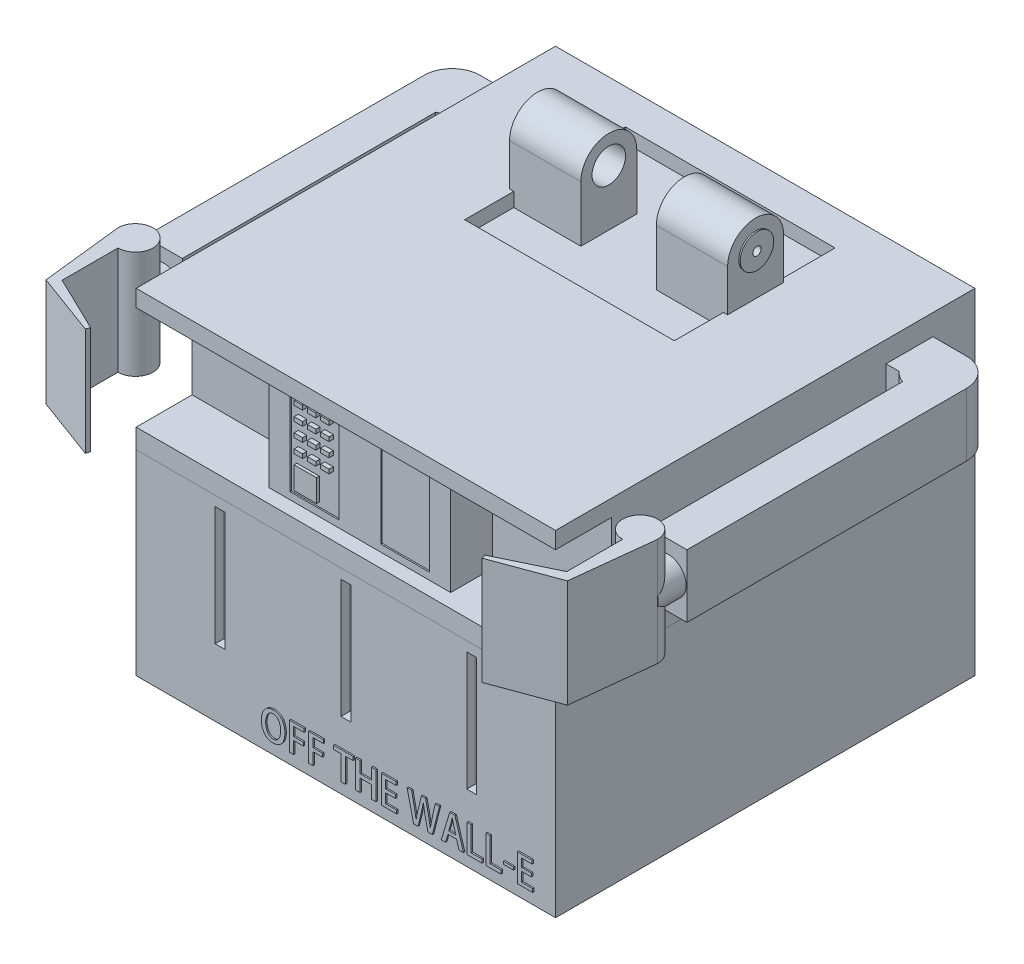
from build123d import *

# Parameters (mm, degrees)
BASE_W                                = 15
BASE_H                                = 15
BOTTOM_BASE_DEPTH                     = 7
BASE2_W                               = 15
BASE2_H                               = 15
TOP_BASE_DEPTH                        = 5
SKETCH3_W                             = 15
SKETCH3_H                             = 3.7
TOP_CUT_DEPTH                         = 2
SKETCH4_W                             = 6.5
SKETCH4_H                             = 3.7
BIG_BUTTON_PLATE_DEPTH                = 1.5
SKETCH6_W                             = 0.3
SKETCH6_H                             = 0.15
F_3X4_BUTTONS_DEPTH                   = 0.1
SKETCH9_W                             = 0.8
SKETCH9_H                             = 0.8
BIG_SQUARE_BUTTON_DEPTH               = 0.1
SKETCH6_6_W                           = 1.75
SKETCH6_6_H                           = 3.2
SKETCH6_6_W_2                         = 0.3
SKETCH6_6_H_2                         = 0.15
PHONE_DEPTH                           = 0.05
SKETCH14_W                            = 0.35
SKETCH14_H                            = 4.25
F_3_BOTTOM_SLOTS_DEPTH                = 0.35
FILLET1_R                             = 0.05
SKETCH15_W                            = 7.5
SKETCH15_H                            = 5.75
TOP_EXTRUDE_CUT_DEPTH                 = 0.5
RIGHT_HEAD_HOLDER_1_DEPTH             = 2.4
RIGHT_HEAD_HOLDER_1_DEPTH_BACK        = 0.15
SKETCH19_R                            = 0.6
RIGHT_HEAD_HOLDER_2_DEPTH             = 0.35
RIGHT_HEAD_HOLDER_2_DEPTH_BACK        = 0.2
SKETCH19_3_R                          = 0.6
SKETCH19_3_R_2                        = 0.15
LEFT_HEAD_HOLDER_1_DEPTH              = 2.4
LEFT_HEAD_HOLDER_1_DEPTH_BACK         = 0.15
SKETCH18_R                            = 0.6
LEFT_HEAD_HOLDER_2_DEPTH              = 0.35
LEFT_HEAD_HOLDER_2_DEPTH_BACK         = 0.2
SKETCH18_3_R                          = 0.6
SKETCH18_3_R_2                        = 0.15
ARMS_DEPTH                            = 2.25
CLAWS_DEPTH                           = 0.8
CLAWS_DEPTH_BACK                      = 3.05
CLAWS_2_DEPTH                         = 0.8
CLAWS_2_DEPTH_BACK                    = 3.05
SKETCH26_R                            = 0.65
CIRCLE_TO_ATTACH_ARMS_AND_CLAWS_DEPTH = 1
SKETCH28_W                            = 0.359189424
SKETCH28_H                            = 0.095238297
BOSS_EXTRUDE26_DEPTH                  = 0.05
SKETCH33_W                            = 1
SKETCH33_H                            = 1
CUT_EXTRUDE1_DEPTH                    = 2.25


with BuildPart() as part:
    # Base → Bottom base (new body)
    with BuildSketch(Plane(origin=(0, 0, 0), x_dir=(1, 0, 0), z_dir=(0, 1, 0))):
        Rectangle(BASE_W, BASE_H)
    extrude(amount=BOTTOM_BASE_DEPTH)

    # Sketch14 → 3 bottom slots (cut)
    with BuildSketch(Plane.XY.offset(7.5)):
        with Locations((0, 4.525)):
            Rectangle(SKETCH14_W, SKETCH14_H)
        with Locations((4.5, 4.525)):
            Rectangle(SKETCH14_W, SKETCH14_H)
        with Locations((-4.5, 4.525)):
            Rectangle(SKETCH14_W, SKETCH14_H)
    extrude(amount=-F_3_BOTTOM_SLOTS_DEPTH, mode=Mode.SUBTRACT)

    # Fillet1
    fillet1_edges = [part.edges().sort_by_distance(p)[0] for p in [
        (-0.175, 4.525, 7.15),
        (-4.675, 4.525, 7.15),
        (4.675, 4.525, 7.15),
        (4.5, 6.65, 7.15),
        (0.175, 4.525, 7.15),
        (0, 6.65, 7.15),
        (4.325, 4.525, 7.15),
        (4.5, 2.4, 7.15),
        (0, 2.4, 7.15),
        (-4.5, 2.4, 7.15),
        (-4.5, 6.65, 7.15),
        (-4.325, 4.525, 7.15),
    ]]
    fillet(fillet1_edges, radius=FILLET1_R)

    # Sketch28 → Boss-Extrude26 (add)
    # profile 1 of 12: a face of its own
    with BuildSketch(Plane.XY.offset(7.5)):
        with BuildLine():
            add(Edge.make_bspline(
                [(-2.542773415, 1.438775136), (-2.55882584, 1.438110923), (-2.59017136, 1.436813916), (-2.635834672, 1.429654226), (-2.678976734, 1.41865114), (-2.719463386, 1.403035452), (-2.757423202, 1.38326681), (-2.792716073, 1.359116703), (-2.825399223, 1.330752787), (-2.855279169, 1.298345473), (-2.882055278, 1.262197262), (-2.905669966, 1.222690536), (-2.925377124, 1.17977718), (-2.941932195, 1.133846801), (-2.954655386, 1.08466898), (-2.964079137, 1.032377645), (-2.969951963, 0.976854424), (-2.97105014, 0.938758011), (-2.971613422, 0.919217401)],
                knots=[0, 0, 0, 0, 1.01693825, 1.985772131, 2.921518734, 3.832117633, 4.727948323, 5.626511184, 6.534414133, 7.463288783, 8.412839634, 9.378967074, 10.373196777, 11.399194858, 12.46754142, 13.586614818, 14.762113956, 16, 16, 16, 16], degree=3))
            add(Edge.make_bspline(
                [(-2.971613422, 0.919217401), (-2.971208289, 0.900429172), (-2.970416523, 0.863710668), (-2.964426968, 0.810220053), (-2.956119813, 0.759588063), (-2.943575482, 0.712087769), (-2.928381776, 0.667333139), (-2.909052276, 0.625858504), (-2.886964026, 0.587076746), (-2.8612577, 0.55170149), (-2.832800775, 0.519545639), (-2.801228268, 0.491619405), (-2.766992422, 0.46781399), (-2.730017847, 0.448191723), (-2.690284694, 0.432873966), (-2.647883002, 0.421784598), (-2.602861971, 0.414647273), (-2.571917352, 0.413420404), (-2.556080466, 0.412792516)],
                knots=[0, 0, 0, 0, 1.222557966, 2.38928844, 3.500048728, 4.559063003, 5.583344684, 6.572073494, 7.532658458, 8.483942143, 9.413076429, 10.322121769, 11.220566177, 12.121066096, 13.040014193, 13.985715855, 14.969126498, 16, 16, 16, 16], degree=3))
            add(Edge.make_bspline(
                [(-2.556080466, 0.412792516), (-2.54075349, 0.413188806), (-2.510669922, 0.41396664), (-2.466682885, 0.420165519), (-2.424842983, 0.430077083), (-2.38526705, 0.444305975), (-2.348009795, 0.462822842), (-2.312864376, 0.485189664), (-2.279982063, 0.511738917), (-2.249253561, 0.542102642), (-2.221648907, 0.576876857), (-2.197202941, 0.615672953), (-2.176945288, 0.65894639), (-2.159942527, 0.706133976), (-2.146555767, 0.757497133), (-2.136920145, 0.812927523), (-2.130587189, 0.872528944), (-2.12942961, 0.913657954), (-2.12883171, 0.934901455)],
                knots=[0, 0, 0, 0, 0.964759122, 1.89361537, 2.791129421, 3.668077106, 4.535429534, 5.405715028, 6.285894481, 7.191747456, 8.120239528, 9.075412678, 10.072429751, 11.12252868, 12.229792465, 13.410030886, 14.662257747, 16, 16, 16, 16], degree=3))
            add(Edge.make_bspline(
                [(-2.12883171, 0.934901455), (-2.129145052, 0.95299104), (-2.12975776, 0.988363246), (-2.134927432, 1.040094869), (-2.143460291, 1.089133126), (-2.154882139, 1.135699503), (-2.169797366, 1.179671389), (-2.188169567, 1.221026594), (-2.209857994, 1.259758826), (-2.234383469, 1.295895008), (-2.262423291, 1.328524563), (-2.293489849, 1.357214635), (-2.327622631, 1.381751634), (-2.365000455, 1.401492806), (-2.405152647, 1.417631026), (-2.44846881, 1.428920554), (-2.494667177, 1.436482788), (-2.526508763, 1.437935279), (-2.542773415, 1.438775136)],
                knots=[0, 0, 0, 0, 1.181997023, 2.311265979, 3.393394717, 4.432710499, 5.441572568, 6.423779709, 7.385757606, 8.339154063, 9.273212536, 10.190881701, 11.096730823, 12.012033381, 12.946898792, 13.918455472, 14.931549697, 16, 16, 16, 16], degree=3))
        make_face()
        with BuildLine():
            add(Edge.make_bspline(
                [(-2.548066636, 1.31991609), (-2.537165417, 1.318983992), (-2.515855441, 1.317161903), (-2.484981242, 1.31054518), (-2.456310213, 1.300351113), (-2.429814447, 1.286594966), (-2.405742403, 1.269172675), (-2.383543332, 1.248629521), (-2.363840451, 1.224383101), (-2.346717009, 1.196948695), (-2.331589955, 1.167451879), (-2.318430785, 1.13658356), (-2.306908464, 1.104796692), (-2.29799648, 1.071757069), (-2.290669647, 1.037788882), (-2.285934581, 1.002655396), (-2.282735348, 0.966518333), (-2.282427136, 0.942026369), (-2.282270891, 0.929610449)],
                knots=[0, 0, 0, 0, 0.999589655, 1.954022852, 2.877517249, 3.773878129, 4.673599429, 5.586311784, 6.531597741, 7.520501744, 8.537853166, 9.559417173, 10.586727125, 11.626167667, 12.685579831, 13.761408337, 14.865171654, 16, 16, 16, 16], degree=3))
            add(Edge.make_bspline(
                [(-2.282270891, 0.929610449), (-2.282515675, 0.916063238), (-2.282995612, 0.889501882), (-2.28596674, 0.850426095), (-2.29128527, 0.813015414), (-2.298562117, 0.777117744), (-2.308300047, 0.742958305), (-2.31968806, 0.710261892), (-2.333651813, 0.679388185), (-2.349250923, 0.650198013), (-2.36712996, 0.623475447), (-2.387135503, 0.599901927), (-2.409359173, 0.579747293), (-2.433601588, 0.563029952), (-2.460016367, 0.549834402), (-2.488459567, 0.540284041), (-2.518878394, 0.533600178), (-2.539982794, 0.532311215), (-2.550789459, 0.531651192)],
                knots=[0, 0, 0, 0, 1.215141369, 2.382468418, 3.512223075, 4.602497428, 5.664896563, 6.695933009, 7.704955915, 8.700973005, 9.661508233, 10.583141316, 11.467103885, 12.344670232, 13.216342825, 14.106081872, 15.030205112, 16, 16, 16, 16], degree=3))
            add(Edge.make_bspline(
                [(-2.550789459, 0.531651192), (-2.561404923, 0.532397393), (-2.582186513, 0.53385821), (-2.612268391, 0.540448671), (-2.640452786, 0.550215414), (-2.666522509, 0.563599601), (-2.690700767, 0.580196186), (-2.712602066, 0.600478458), (-2.732893267, 0.623866029), (-2.750494325, 0.650723065), (-2.766275355, 0.679738522), (-2.7800325, 0.710402286), (-2.791879883, 0.742433556), (-2.80114964, 0.77598823), (-2.808854497, 0.810774186), (-2.814005122, 0.846973579), (-2.817330483, 0.884511626), (-2.817764383, 0.910013807), (-2.817985276, 0.922996691)],
                knots=[0, 0, 0, 0, 0.968573833, 1.896149455, 2.796477749, 3.679461465, 4.558257033, 5.460120664, 6.392036362, 7.372592241, 8.379386201, 9.399199485, 10.432362265, 11.48798156, 12.568687675, 13.676620176, 14.817192429, 16, 16, 16, 16], degree=3))
            add(Edge.make_bspline(
                [(-2.817985276, 0.922996691), (-2.817906472, 0.93566455), (-2.817750586, 0.960723784), (-2.814512109, 0.997678677), (-2.809767876, 1.033623912), (-2.802495327, 1.068302048), (-2.793463414, 1.101907221), (-2.782305831, 1.13439706), (-2.768830302, 1.165645515), (-2.753760089, 1.19566964), (-2.736462485, 1.223413999), (-2.716446665, 1.247918927), (-2.69405673, 1.268812858), (-2.669357094, 1.286293929), (-2.642284347, 1.300124753), (-2.612952929, 1.310551542), (-2.58132124, 1.317484158), (-2.559390721, 1.319029602), (-2.548066636, 1.31991609)],
                knots=[0, 0, 0, 0, 1.136547726, 2.248289582, 3.326834991, 4.389002452, 5.425786828, 6.448433384, 7.469124786, 8.477926495, 9.461316408, 10.397265518, 11.309260955, 12.201738065, 13.104381261, 14.028854752, 14.989125284, 16, 16, 16, 16], degree=3))
        make_face(mode=Mode.SUBTRACT)
    # profile 2 of 12: a face of its own
    with BuildSketch(Plane.XY.offset(7.5)):
        Polygon((-1.814205801, 0.421490419), (-1.814205801, 0.860354587), (-1.471996241, 0.860354587), (-1.471996241, 0.979213633), (-1.814205801, 0.979213633), (-1.814205801, 1.295728633), (-1.445873374, 1.295728633), (-1.445873374, 1.414587678), (-1.967645167, 1.414587678), (-1.967645167, 0.421490419), align=None)
    # profile 3 of 12: a face of its own
    with BuildSketch(Plane.XY.offset(7.5)):
        Polygon((-1.12486327, 0.421490419), (-1.12486327, 0.860354587), (-0.782653711, 0.860354587), (-0.782653711, 0.979213633), (-1.12486327, 0.979213633), (-1.12486327, 1.295728633), (-0.756530843, 1.295728633), (-0.756530843, 1.414587678), (-1.278302637, 1.414587678), (-1.278302637, 0.421490419), align=None)
    # profile 4 of 12: a face of its own
    with BuildSketch(Plane.XY.offset(7.5)):
        Polygon((0.306506351, 1.425859116), (-0.386370222, 1.425859116), (-0.386370222, 1.296550924), (-0.11730469, 1.296550924), (-0.11730469, 0.426659447), (0.036134676, 0.426659447), (0.036134676, 1.296550924), (0.306506351, 1.296550924), align=None)
    # profile 5 of 12: a face of its own
    with BuildSketch(Plane.XY.offset(7.5)):
        Polygon((1.124570067, 1.428519382), (0.971130701, 1.428519382), (0.971130701, 1.015778081), (0.556165007, 1.015778081), (0.556165007, 1.428519382), (0.40272564, 1.428519382), (0.40272564, 0.429720894), (0.556165007, 0.429720894), (0.556165007, 0.884258782), (0.971130701, 0.884258782), (0.971130701, 0.429720894), (1.124570067, 0.429720894), align=None)
    # profile 6 of 12: a face of its own
    with BuildSketch(Plane.XY.offset(7.5)):
        Polygon((1.868437532, 0.543839587), (1.475288381, 0.543839587), (1.475288381, 0.884542045), (1.825334801, 0.884542045), (1.825334801, 1.00340109), (1.475288381, 1.00340109), (1.475288381, 1.295728633), (1.846233095, 1.295728633), (1.846233095, 1.414587678), (1.321849015, 1.414587678), (1.321849015, 0.424980542), (1.868437532, 0.424980542), align=None)
    # profile 7 of 12: a face of its own
    with BuildSketch(Plane.XY.offset(7.5)):
        with BuildLine():
            Line((3.245765887, 1.425831067), (3.139055562, 0.953960298))
            add(Edge.make_bspline(
                [(3.139055562, 0.953960298), (3.132663135, 0.924375836), (3.119998725, 0.865764336), (3.1020337, 0.778168135), (3.085930576, 0.690954756), (3.07705063, 0.63264649), (3.07260538, 0.603457706)],
                knots=[0, 0, 0, 0, 1.01788206, 2.01658543, 3.007114032, 4, 4, 4, 4], degree=3))
            Line((3.07260538, 0.603457706), (3.068782909, 0.603457706))
            add(Edge.make_bspline(
                [(3.068782909, 0.603457706), (3.064621305, 0.632259681), (3.056258443, 0.690138076), (3.041702599, 0.777037426), (3.025081799, 0.864413942), (3.012568145, 0.922642729), (3.006278837, 0.951908261)],
                knots=[0, 0, 0, 0, 0.986163973, 1.981724799, 2.985623747, 4, 4, 4, 4], degree=3))
            Line((3.006278837, 0.951908261), (2.902210694, 1.426964854))
            Line((2.902210694, 1.426964854), (2.751254624, 1.426964854))
            Line((2.751254624, 1.426964854), (2.638037571, 0.954592148))
            add(Edge.make_bspline(
                [(2.638037571, 0.954592148), (2.630872403, 0.923406884), (2.61681508, 0.862224604), (2.596699251, 0.772299255), (2.578665214, 0.686135246), (2.569505115, 0.629634853), (2.565046708, 0.602134954)],
                knots=[0, 0, 0, 0, 1.066520868, 2.092404214, 3.071534041, 4, 4, 4, 4], degree=3))
            Line((2.565046708, 0.602134954), (2.562559536, 0.602140121))
            add(Edge.make_bspline(
                [(2.562559536, 0.602140121), (2.560300099, 0.615428557), (2.55570602, 0.642447728), (2.54874011, 0.683653591), (2.541417455, 0.726190662), (2.530665073, 0.785077644), (2.516739752, 0.860534551), (2.504767173, 0.921245095), (2.498720165, 0.951908261)],
                knots=[0, 0, 0, 0, 0.682369738, 1.387451828, 2.115611866, 2.867419731, 4.417822979, 6, 6, 6, 6], degree=3))
            Line((2.498720165, 0.951908261), (2.399891357, 1.426964854))
            Line((2.399891357, 1.426964854), (2.239838602, 1.426964854))
            Line((2.239838602, 1.426964854), (2.472766701, 0.425831067))
            Line((2.472766701, 0.425831067), (2.631530844, 0.425831067))
            Line((2.631530844, 0.425831067), (2.749953278, 0.910045241))
            add(Edge.make_bspline(
                [(2.749953278, 0.910045241), (2.753617344, 0.924555813), (2.760831191, 0.953124366), (2.770726599, 0.995475919), (2.780283244, 1.03650652), (2.791843212, 1.089662653), (2.80499902, 1.155496718), (2.813336322, 1.208364765), (2.817503292, 1.234788132)],
                knots=[0, 0, 0, 0, 0.811805786, 1.598290927, 2.359154387, 3.097023541, 4.549096894, 6, 6, 6, 6], degree=3))
            Line((2.817503292, 1.234788132), (2.821527277, 1.234976727))
            add(Edge.make_bspline(
                [(2.821527277, 1.234976727), (2.82469568, 1.208365765), (2.831034187, 1.155129548), (2.844522693, 1.075106184), (2.860318642, 0.993345399), (2.872490004, 0.938213226), (2.878727794, 0.90995814)],
                knots=[0, 0, 0, 0, 0.973823886, 1.948170723, 2.948443182, 4, 4, 4, 4], degree=3))
            Line((2.878727794, 0.90995814), (2.986798147, 0.425831067))
            Line((2.986798147, 0.425831067), (3.144260944, 0.425831067))
            Line((3.144260944, 0.425831067), (3.399324648, 1.426964854))
            Line((3.399324648, 1.426964854), (3.245765887, 1.425831067))
        make_face()
    # profile 8 of 12: a face of its own
    with BuildSketch(Plane.XY.offset(7.5)):
        Polygon((3.9523852, 1.426512188), (3.766939047, 1.426512188), (3.461305192, 0.421347588), (3.616753782, 0.421347588), (3.702947065, 0.715229844), (4.008541429, 0.715229844), (4.098652588, 0.421347588), (4.257979564, 0.421347588), align=None)
        with BuildLine():
            Line((3.726454323, 0.83408889), (3.806117812, 1.098552471))
            add(Edge.make_bspline(
                [(3.806117812, 1.098552471), (3.810378493, 1.114590054), (3.819076241, 1.147329146), (3.83055211, 1.197153881), (3.841903727, 1.246876142), (3.849377993, 1.279761021), (3.853028805, 1.295823669)],
                knots=[0, 0, 0, 0, 0.981880665, 2.004409445, 3.025252049, 4, 4, 4, 4], degree=3))
            Line((3.853028805, 1.295823669), (3.855744247, 1.295897852))
            add(Edge.make_bspline(
                [(3.855744247, 1.295897852), (3.859406222, 1.279929837), (3.866906617, 1.247224421), (3.878892873, 1.19768297), (3.891585867, 1.147389791), (3.900662415, 1.113901091), (3.905183009, 1.097221969)],
                knots=[0, 0, 0, 0, 0.960134074, 1.966530216, 2.987225846, 4, 4, 4, 4], degree=3))
            Line((3.905183009, 1.097221969), (3.983728212, 0.83408889))
            Line((3.983728212, 0.83408889), (3.726454323, 0.83408889))
        make_face(mode=Mode.SUBTRACT)
    # profile 9 of 12: a face of its own
    with BuildSketch(Plane.XY.offset(7.5)):
        Polygon((4.92031401, 0.555082791), (4.53500172, 0.555082791), (4.53500172, 1.426280411), (4.381562353, 1.426280411), (4.381562353, 0.425831067), (4.92031401, 0.425831067), align=None)
    # profile 10 of 12: a face of its own
    with BuildSketch(Plane.XY.offset(7.5)):
        Polygon((5.597562813, 0.555082791), (5.212250522, 0.555082791), (5.212250522, 1.426280411), (5.058811156, 1.426280411), (5.058811156, 0.425831067), (5.597562813, 0.425831067), align=None)
    # profile 11 of 12: a face of its own
    with BuildSketch(Plane.XY.offset(7.5)):
        with Locations((5.867201512, 0.823034374)):
            Rectangle(SKETCH28_W, SKETCH28_H)
    # profile 12 of 12: a face of its own
    with BuildSketch(Plane.XY.offset(7.5)):
        Polygon((6.730116434, 0.543839587), (6.336967283, 0.543839587), (6.336967283, 0.884542045), (6.687013703, 0.884542045), (6.687013703, 1.00340109), (6.336967283, 1.00340109), (6.336967283, 1.295728633), (6.707911996, 1.295728633), (6.707911996, 1.414587678), (6.183527917, 1.414587678), (6.183527917, 0.424980542), (6.730116434, 0.424980542), align=None)
    extrude(amount=BOSS_EXTRUDE26_DEPTH)

    # Sketch33 → Cut-Extrude1 (cut)
    with BuildSketch(Plane.XZ):
        with Locations((-6.5, 0.1)):
            Rectangle(SKETCH33_W, SKETCH33_H)
        with Locations((6.5, 0.1)):
            Rectangle(SKETCH33_W, SKETCH33_H)
    extrude(amount=-CUT_EXTRUDE1_DEPTH, mode=Mode.SUBTRACT)


with BuildPart() as body_2:
    # Base2 → Top base (new body)
    with BuildSketch(Plane(origin=(0, 7, 0), x_dir=(1, 0, 0), z_dir=(0, 1, 0))):
        Rectangle(BASE2_W, BASE2_H)
    extrude(amount=TOP_BASE_DEPTH)

    # Sketch3 → Top cut (cut)
    with BuildSketch(Plane.XY.offset(7.5)):
        with Locations((0, 9.55)):
            Rectangle(SKETCH3_W, SKETCH3_H)
    extrude(amount=-TOP_CUT_DEPTH, mode=Mode.SUBTRACT)

    # Sketch4 → Big button plate (add)
    with BuildSketch(Plane.XY.offset(5.5)):
        with Locations((0, 9.55)):
            Rectangle(SKETCH4_W, SKETCH4_H)
    extrude(amount=BIG_BUTTON_PLATE_DEPTH)

    # Sketch6 → 3x4 buttons (add)
    with BuildSketch(Plane.XY.offset(7)):
        with Locations((-1.625, 10.874059361)):
            Rectangle(SKETCH6_W, SKETCH6_H)
        with Locations((-2.1, 10.874059361)):
            Rectangle(SKETCH6_W, SKETCH6_H)
        with Locations((-1.15, 10.874059361)):
            Rectangle(SKETCH6_W, SKETCH6_H)
        with Locations((-2.1, 10.374059361)):
            Rectangle(SKETCH6_W, SKETCH6_H)
        with Locations((-1.625, 10.374059361)):
            Rectangle(SKETCH6_W, SKETCH6_H)
        with Locations((-1.15, 10.374059361)):
            Rectangle(SKETCH6_W, SKETCH6_H)
        with Locations((-2.1, 9.874059361)):
            Rectangle(SKETCH6_W, SKETCH6_H)
        with Locations((-1.625, 9.874059361)):
            Rectangle(SKETCH6_W, SKETCH6_H)
        with Locations((-1.15, 9.874059361)):
            Rectangle(SKETCH6_W, SKETCH6_H)
        with Locations((-2.1, 9.374059361)):
            Rectangle(SKETCH6_W, SKETCH6_H)
        with Locations((-1.625, 9.374059361)):
            Rectangle(SKETCH6_W, SKETCH6_H)
        with Locations((-1.15, 9.374059361)):
            Rectangle(SKETCH6_W, SKETCH6_H)
    extrude(amount=F_3X4_BUTTONS_DEPTH)

    # Sketch9 → Big square button (add)
    with BuildSketch(Plane.XY.offset(7)):
        with Locations((-1.85, 8.55732297)):
            Rectangle(SKETCH9_W, SKETCH9_H)
    extrude(amount=BIG_SQUARE_BUTTON_DEPTH)

    # Sketch6_6 → phone (cut)
    # profile 1 of 2: a face of its own
    with BuildSketch(Plane.XY.offset(7)):
        with Locations((-1.625, 9.55)):
            Rectangle(SKETCH6_6_W, SKETCH6_6_H)
        with Locations((-1.625, 10.874059361)):
            Rectangle(SKETCH6_6_W_2, SKETCH6_6_H_2, mode=Mode.SUBTRACT)
        with Locations((-2.1, 10.874059361)):
            Rectangle(SKETCH6_6_W_2, SKETCH6_6_H_2, mode=Mode.SUBTRACT)
        with Locations((-1.15, 10.874059361)):
            Rectangle(SKETCH6_6_W_2, SKETCH6_6_H_2, mode=Mode.SUBTRACT)
        with Locations((-2.1, 10.374059361)):
            Rectangle(SKETCH6_6_W_2, SKETCH6_6_H_2, mode=Mode.SUBTRACT)
        with Locations((-1.625, 10.374059361)):
            Rectangle(SKETCH6_6_W_2, SKETCH6_6_H_2, mode=Mode.SUBTRACT)
        with Locations((-1.15, 10.374059361)):
            Rectangle(SKETCH6_6_W_2, SKETCH6_6_H_2, mode=Mode.SUBTRACT)
        with Locations((-2.1, 9.874059361)):
            Rectangle(SKETCH6_6_W_2, SKETCH6_6_H_2, mode=Mode.SUBTRACT)
        with Locations((-1.625, 9.874059361)):
            Rectangle(SKETCH6_6_W_2, SKETCH6_6_H_2, mode=Mode.SUBTRACT)
        with Locations((-1.15, 9.874059361)):
            Rectangle(SKETCH6_6_W_2, SKETCH6_6_H_2, mode=Mode.SUBTRACT)
        with Locations((-2.1, 9.374059361)):
            Rectangle(SKETCH6_6_W_2, SKETCH6_6_H_2, mode=Mode.SUBTRACT)
        with Locations((-1.625, 9.374059361)):
            Rectangle(SKETCH6_6_W_2, SKETCH6_6_H_2, mode=Mode.SUBTRACT)
        with Locations((-1.15, 9.374059361)):
            Rectangle(SKETCH6_6_W_2, SKETCH6_6_H_2, mode=Mode.SUBTRACT)
    # profile 2 of 2: a face of its own
    with BuildSketch(Plane.XY.offset(7)):
        with Locations((1.625, 9.55)):
            Rectangle(SKETCH6_6_W, SKETCH6_6_H)
    extrude(amount=-PHONE_DEPTH, mode=Mode.SUBTRACT)


with BuildPart() as phone_piece_1:
    # of the separate pieces the step leaves, piece 1, a body of its own (phone_pieces)
    add(body_2.part.solids().sort_by_distance((-7.5, 7, 7.5))[0])

    # Sketch15 → Top extrude cut (cut)
    with BuildSketch(Plane(origin=(0, 12, 0), x_dir=(1, 0, 0), z_dir=(0, 1, 0))):
        with Locations((0, 3.375)):
            Rectangle(SKETCH15_W, SKETCH15_H)
    extrude(amount=-TOP_EXTRUDE_CUT_DEPTH, mode=Mode.SUBTRACT)

    # Sketch19 → Right head holder 1 (add, two sides: drawn at the far end of the back side and taken through both)
    with BuildSketch(Plane.ZY.offset(-3.75).offset(-RIGHT_HEAD_HOLDER_1_DEPTH_BACK)):
        with BuildLine():
            ThreePointArc((-2.255590817, 13.5), (-3.255590817, 14.5), (-4.255590817, 13.5))
            Line((-4.255590817, 13.5), (-4.255590817, 11.5))
            Line((-4.255590817, 11.5), (-2.255590817, 11.5))
            Line((-2.255590817, 11.5), (-2.255590817, 13.5))
        make_face()
        with Locations((-3.255590817, 13.5)):
            Circle(SKETCH19_R, mode=Mode.SUBTRACT)
    extrude(amount=RIGHT_HEAD_HOLDER_1_DEPTH + RIGHT_HEAD_HOLDER_1_DEPTH_BACK)

    # Sketch19_3 → Right head holder 2 (add, two sides: drawn at the far end of the back side and taken through both)
    with BuildSketch(Plane.ZY.offset(-3.75).offset(-RIGHT_HEAD_HOLDER_2_DEPTH_BACK)):
        with Locations((-3.255590817, 13.5)):
            Circle(SKETCH19_3_R)
        with Locations((-3.255590817, 13.5)):
            Circle(SKETCH19_3_R_2, mode=Mode.SUBTRACT)
    extrude(amount=RIGHT_HEAD_HOLDER_2_DEPTH + RIGHT_HEAD_HOLDER_2_DEPTH_BACK)

    # Sketch18 → Left head holder 1 (add, two sides: drawn at the far end of the back side and taken through both)
    with BuildSketch(Plane(origin=(-3.75, 0, 0), x_dir=(0, 0, -1), z_dir=(1, 0, 0)).offset(-LEFT_HEAD_HOLDER_1_DEPTH_BACK)):
        with BuildLine():
            Line((2.255590817, 11.5), (4.255590817, 11.5))
            Line((4.255590817, 11.5), (4.255590817, 13.5))
            ThreePointArc((4.255590817, 13.5), (3.255590817, 14.5), (2.255590817, 13.5))
            Line((2.255590817, 13.5), (2.255590817, 11.5))
        make_face()
        with Locations((3.255590817, 13.5)):
            Circle(SKETCH18_R, mode=Mode.SUBTRACT)
    extrude(amount=LEFT_HEAD_HOLDER_1_DEPTH + LEFT_HEAD_HOLDER_1_DEPTH_BACK)

    # Sketch18_3 → Left head holder 2 (add, two sides: drawn at the far end of the back side and taken through both)
    with BuildSketch(Plane(origin=(-3.75, 0, 0), x_dir=(0, 0, -1), z_dir=(1, 0, 0)).offset(-LEFT_HEAD_HOLDER_2_DEPTH_BACK)):
        with Locations((3.255590817, 13.5)):
            Circle(SKETCH18_3_R)
        with Locations((3.255590817, 13.5)):
            Circle(SKETCH18_3_R_2, mode=Mode.SUBTRACT)
    extrude(amount=LEFT_HEAD_HOLDER_2_DEPTH + LEFT_HEAD_HOLDER_2_DEPTH_BACK)

    # Sketch21 → arms (add)
    with BuildSketch(Plane(origin=(0, 9, 0), x_dir=(1, 0, 0), z_dir=(0, 1, 0))):
        with BuildLine():
            Line((7.5, 4.322915521), (7.964094701, 4.322915521))
            ThreePointArc((7.964094701, 4.322915521), (8.141740127, 4.170333854), (8.35, 4.0632503))
            Line((8.35, 4.0632503), (8.35, -5))
            Line((8.35, -5), (9.7, -5))
            Line((9.7, -5), (9.7, 5))
            ThreePointArc((9.7, 5), (9.407106781, 5.707106781), (8.7, 6))
            Line((8.7, 6), (7.5, 6))
            Line((7.5, 6), (7.5, 4.322915521))
        make_face()
        with BuildLine():
            Line((-7.5, 6), (-8.7, 6))
            ThreePointArc((-8.7, 6), (-9.407106781, 5.707106781), (-9.7, 5))
            Line((-9.7, 5), (-9.7, -5))
            Line((-9.7, -5), (-8.35, -5))
            Line((-8.35, -5), (-8.35, 4.0632503))
            ThreePointArc((-8.35, 4.0632503), (-8.141740127, 4.170333854), (-7.964094701, 4.322915521))
            Line((-7.964094701, 4.322915521), (-7.5, 4.322915521))
            Line((-7.5, 4.322915521), (-7.5, 6))
        make_face()
    extrude(amount=ARMS_DEPTH)



with BuildPart() as phone_piece_2:
    # of the separate pieces the step leaves, piece 2, a body of its own (phone_pieces)
    add(body_2.part.solids().sort_by_distance((-2.25, 8.95732297, 7))[0])


with BuildPart() as body_4:
    # Sketch25 → claws (new, two sides: drawn at the far end of the back side and taken through both)
    with BuildSketch(Plane(origin=(0, 11.25, 0), x_dir=(1, 0, 0), z_dir=(0, 1, 0)).offset(-CLAWS_DEPTH_BACK)):
        with BuildLine():
            ThreePointArc((9.65, -6), (8.583058262, -5.558058262), (9.025, -6.625))
            Line((9.025, -6.625), (9.025, -8.625))
            Line((9.025, -8.625), (7.048208811, -9.580762133))
            Line((7.048208811, -9.580762133), (7.100145112, -9.721483918))
            Line((7.100145112, -9.721483918), (9.325961764, -8.9))
            Line((9.325961764, -8.9), (9.65, -6))
        make_face()
    extrude(amount=CLAWS_DEPTH + CLAWS_DEPTH_BACK)


with BuildPart() as body_5:
    # Sketch25 → claws 2 (new, two sides: drawn at the far end of the back side and taken through both)
    with BuildSketch(Plane(origin=(0, 11.25, 0), x_dir=(1, 0, 0), z_dir=(0, 1, 0)).offset(-CLAWS_2_DEPTH_BACK)):
        with BuildLine():
            Line((-9.325961764, -8.9), (-7.100145112, -9.721483918))
            Line((-7.100145112, -9.721483918), (-7.048208811, -9.580762133))
            Line((-7.048208811, -9.580762133), (-9.025, -8.625))
            Line((-9.025, -8.625), (-9.025, -6.625))
            ThreePointArc((-9.025, -6.625), (-8.583058262, -5.558058262), (-9.65, -6))
            Line((-9.65, -6), (-9.325961764, -8.9))
        make_face()
    extrude(amount=CLAWS_2_DEPTH + CLAWS_2_DEPTH_BACK)


with BuildPart() as phone_piece_1_1:
    add(phone_piece_1.part)

    add(body_4.part)  # circle to attach arms and claws merges body 4

    add(body_5.part)  # circle to attach arms and claws merges body 5
    # Sketch26 → circle to attach arms and claws (add)
    with BuildSketch(Plane.XY.offset(5)):
        with Locations((9.025, 10.125)):
            Circle(SKETCH26_R)
        with Locations((-9.025, 10.125)):
            Circle(SKETCH26_R)
    extrude(amount=CIRCLE_TO_ATTACH_ARMS_AND_CLAWS_DEPTH)


solid = Compound([part.part, phone_piece_2.part, phone_piece_1_1.part])
